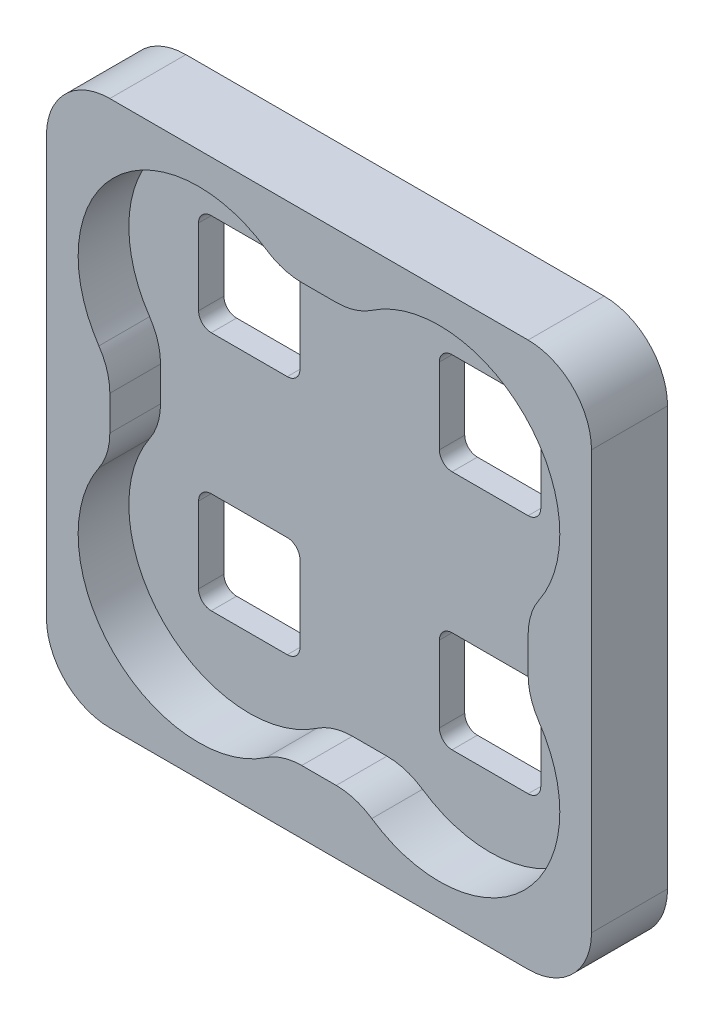
from build123d import *

# Parameters (mm, degrees)
DODANIE_WYCI_GNI_CIE1_DEPTH = 6
WYTNIJ_WYCI_GNI_CIE2_DEPTH  = 4
WYTNIJ_WYCI_GNI_CIE3_DEPTH  = 2


with BuildPart() as part:
    # Szkic1 → Dodanie-wyciągnięcie1 (new body)
    with BuildSketch(Plane.XY):
        with BuildLine():
            Line((-16.5, 21.5), (16.5, 21.5))
            ThreePointArc((16.5, 21.5), (20.035533906, 20.035533906), (21.5, 16.5))
            Line((21.5, 16.5), (21.5, -16.5))
            ThreePointArc((21.5, -16.5), (20.035533906, -20.035533906), (16.5, -21.5))
            Line((16.5, -21.5), (-16.5, -21.5))
            ThreePointArc((-16.5, -21.5), (-20.035533906, -20.035533906), (-21.5, -16.5))
            Line((-21.5, -16.5), (-21.5, 16.5))
            ThreePointArc((-21.5, 16.5), (-20.035533906, 20.035533906), (-16.5, 21.5))
        make_face()
    extrude(amount=DODANIE_WYCI_GNI_CIE1_DEPTH)

    # Szkic2 → Wytnij-wyciągnięcie2 (cut)
    with BuildSketch(Plane.XY.offset(6)):
        with BuildLine():
            Line((-16.5, 1.360589702), (-16.5, -1.360589702))
            ThreePointArc((-16.5, -1.360589702), (-16.720373698, -2.828640251), (-17.362068966, -4.167282908))
            ThreePointArc((-17.362068966, -4.167282908), (-16.217514421, -16.217514421), (-4.167282908, -17.362068966))
            ThreePointArc((-4.167282908, -17.362068966), (-2.828640251, -16.720373698), (-1.360589702, -16.5))
            Line((-1.360589702, -16.5), (1.360589702, -16.5))
            ThreePointArc((1.360589702, -16.5), (2.828640251, -16.720373698), (4.167282908, -17.362068966))
            ThreePointArc((4.167282908, -17.362068966), (16.217514421, -16.217514421), (17.362068966, -4.167282908))
            ThreePointArc((17.362068966, -4.167282908), (16.720373698, -2.828640251), (16.5, -1.360589702))
            Line((16.5, -1.360589702), (16.5, 1.360589702))
            ThreePointArc((16.5, 1.360589702), (16.720373698, 2.828640251), (17.362068966, 4.167282908))
            ThreePointArc((17.362068966, 4.167282908), (16.217514421, 16.217514421), (4.167282908, 17.362068966))
            ThreePointArc((4.167282908, 17.362068966), (2.828640251, 16.720373698), (1.360589702, 16.5))
            Line((1.360589702, 16.5), (-1.360589702, 16.5))
            ThreePointArc((-1.360589702, 16.5), (-2.828640251, 16.720373698), (-4.167282908, 17.362068966))
            ThreePointArc((-4.167282908, 17.362068966), (-16.217514421, 16.217514421), (-17.362068966, 4.167282908))
            ThreePointArc((-17.362068966, 4.167282908), (-16.720373698, 2.828640251), (-16.5, 1.360589702))
        make_face()
    extrude(amount=-WYTNIJ_WYCI_GNI_CIE2_DEPTH, mode=Mode.SUBTRACT)

    # Szkic3 → Wytnij-wyciągnięcie3 (cut)
    with BuildSketch(Plane.XY.offset(2)):
        with BuildLine():
            Line((6.5, -5.5), (12.5, -5.5))
            ThreePointArc((12.5, -5.5), (13.207106781, -5.792893219), (13.5, -6.5))
            Line((13.5, -6.5), (13.5, -12.5))
            ThreePointArc((13.5, -12.5), (13.207106781, -13.207106781), (12.5, -13.5))
            Line((12.5, -13.5), (6.5, -13.5))
            ThreePointArc((6.5, -13.5), (5.792893219, -13.207106781), (5.5, -12.5))
            Line((5.5, -12.5), (5.5, -6.5))
            ThreePointArc((5.5, -6.5), (5.792893219, -5.792893219), (6.5, -5.5))
        make_face()
        with BuildLine():
            Line((6.5, 13.5), (12.5, 13.5))
            ThreePointArc((12.5, 13.5), (13.207106781, 13.207106781), (13.5, 12.5))
            Line((13.5, 12.5), (13.5, 6.5))
            ThreePointArc((13.5, 6.5), (13.207106781, 5.792893219), (12.5, 5.5))
            Line((12.5, 5.5), (6.5, 5.5))
            ThreePointArc((6.5, 5.5), (5.792893219, 5.792893219), (5.5, 6.5))
            Line((5.5, 6.5), (5.5, 12.5))
            ThreePointArc((5.5, 12.5), (5.792893219, 13.207106781), (6.5, 13.5))
        make_face()
        with BuildLine():
            Line((-12.5, -5.5), (-6.5, -5.5))
            ThreePointArc((-6.5, -5.5), (-5.792893219, -5.792893219), (-5.5, -6.5))
            Line((-5.5, -6.5), (-5.5, -12.5))
            ThreePointArc((-5.5, -12.5), (-5.792893219, -13.207106781), (-6.5, -13.5))
            Line((-6.5, -13.5), (-12.5, -13.5))
            ThreePointArc((-12.5, -13.5), (-13.207106781, -13.207106781), (-13.5, -12.5))
            Line((-13.5, -12.5), (-13.5, -6.5))
            ThreePointArc((-13.5, -6.5), (-13.207106781, -5.792893219), (-12.5, -5.5))
        make_face()
        with BuildLine():
            Line((-12.5, 13.5), (-6.5, 13.5))
            ThreePointArc((-6.5, 13.5), (-5.792893219, 13.207106781), (-5.5, 12.5))
            Line((-5.5, 12.5), (-5.5, 6.5))
            ThreePointArc((-5.5, 6.5), (-5.792893219, 5.792893219), (-6.5, 5.5))
            Line((-6.5, 5.5), (-12.5, 5.5))
            ThreePointArc((-12.5, 5.5), (-13.207106781, 5.792893219), (-13.5, 6.5))
            Line((-13.5, 6.5), (-13.5, 12.5))
            ThreePointArc((-13.5, 12.5), (-13.207106781, 13.207106781), (-12.5, 13.5))
        make_face()
    extrude(amount=-WYTNIJ_WYCI_GNI_CIE3_DEPTH, mode=Mode.SUBTRACT)


solid = part.part
